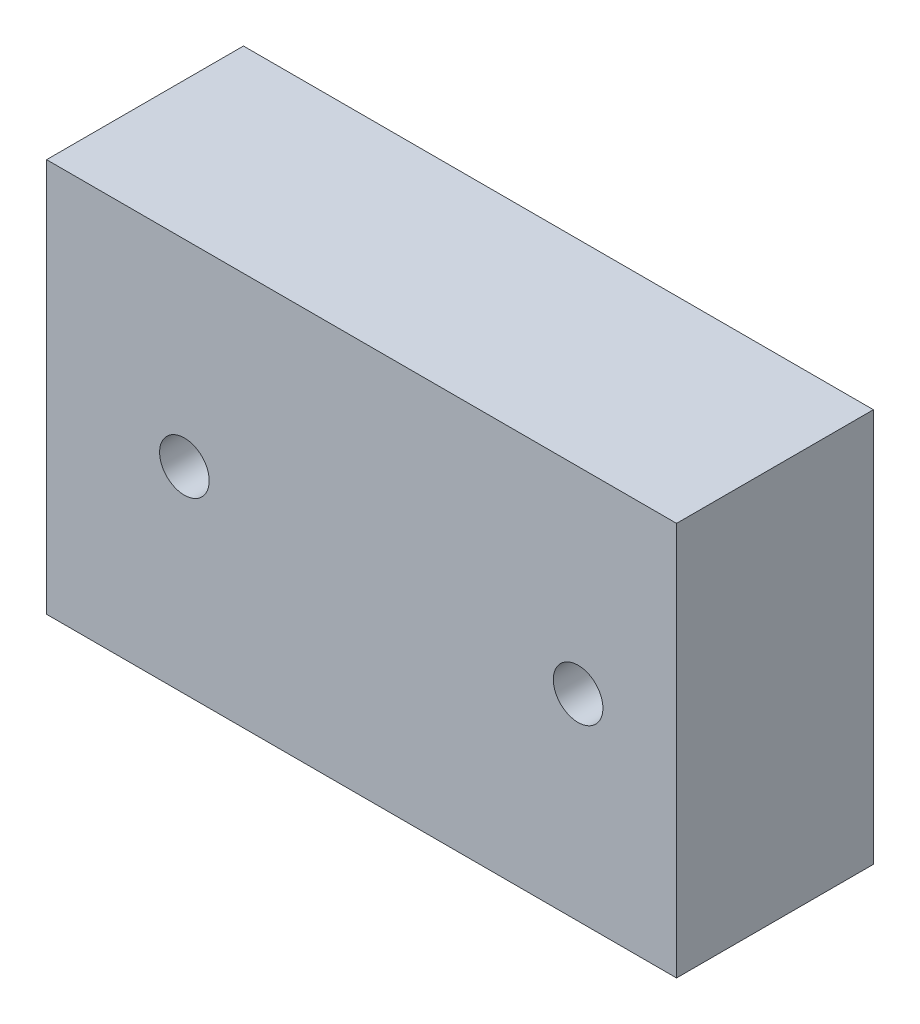
from build123d import *

# Parameters (mm, degrees)
SKETCH1_W             = 20.32
SKETCH1_H             = 12.7
BOSS_EXTRUDE1_DEPTH   = 6.35
M2X0_4_TAPPED_HOLE1_D = 1.6


with BuildPart() as part:
    # Sketch1 → Boss-Extrude1 (new body)
    with BuildSketch(Plane.XY):
        with Locations((10.16, 6.35)):
            Rectangle(SKETCH1_W, SKETCH1_H)
    extrude(amount=BOSS_EXTRUDE1_DEPTH)

    # M2x0.4 Tapped Hole1 (through all)
    with Locations(Plane.XY.offset(6.35)):
        with Locations((17.145, 6.35), (4.445, 6.35)):
            Hole(M2X0_4_TAPPED_HOLE1_D / 2)


solid = part.part
